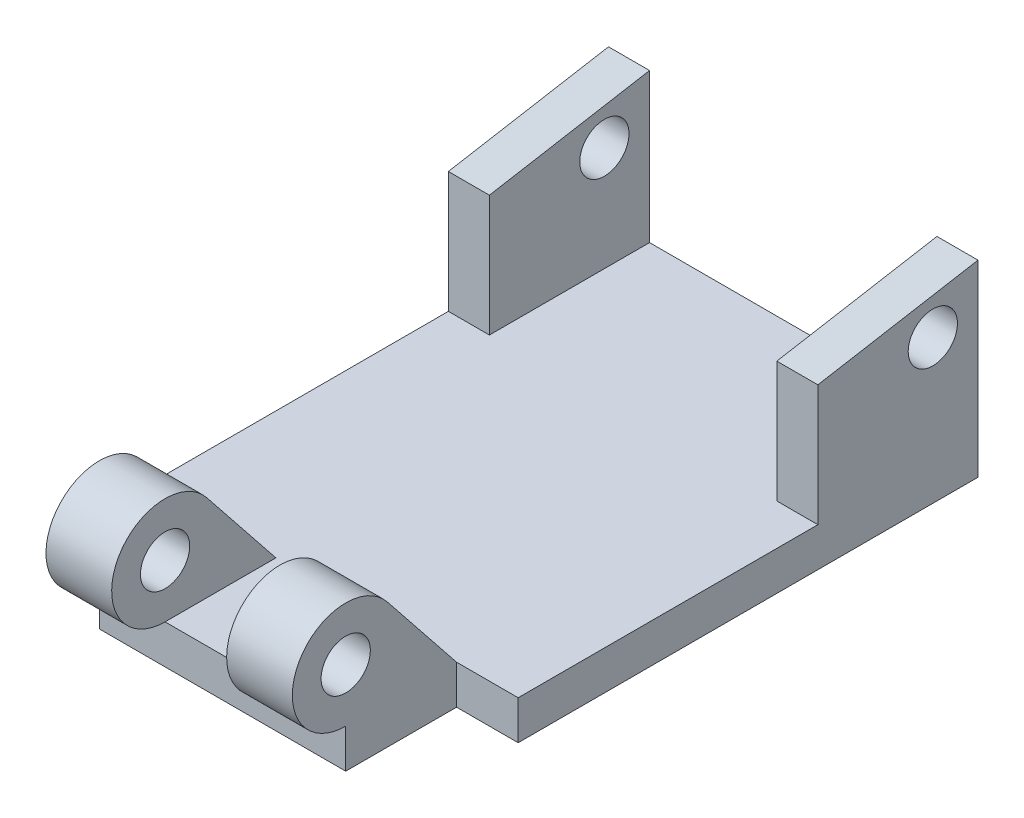
from build123d import *

# Parameters (mm, degrees)
SKETCH1_W           = 57.15
SKETCH1_H           = 71.12
SKETCH1_W_2         = 38.1
SKETCH1_H_2         = 17.145
BOSS_EXTRUDE1_DEPTH = 6.0325
SKETCH2_R           = 8.255
SKETCH2_R_2         = 3.81
BOSS_EXTRUDE2_DEPTH = 38.1
SKETCH3_W           = 17.78
SKETCH3_H           = 25.4
CUT_EXTRUDE1_DEPTH  = 35.7505
SKETCH4_R           = 3.81
BOSS_EXTRUDE3_DEPTH = 57.15
SKETCH5_W           = 44.45
SKETCH5_H           = 23.0505
CUT_EXTRUDE2_DEPTH  = 35.7505


with BuildPart() as part:
    # Sketch1 → Boss-Extrude1 (new body)
    with BuildSketch(Plane(origin=(0, 0, 0), x_dir=(1, 0, 0), z_dir=(0, 1, 0))):
        with Locations((28.575, 35.56)):
            Rectangle(SKETCH1_W, SKETCH1_H)
        with Locations((28.575, -8.5725)):
            Rectangle(SKETCH1_W_2, SKETCH1_H_2)
    extrude(amount=BOSS_EXTRUDE1_DEPTH)

    # Sketch2 → Boss-Extrude2 (add)
    with BuildSketch(Plane.ZY.offset(-9.525)):
        with BuildLine():
            Line((10.691759465, 19.435384187), (0, 6.0325))
            Line((0, 6.0325), (17.145, 6.0325))
            ThreePointArc((17.145, 6.0325), (9.707231216, 10.706352067), (10.691759465, 19.435384187))
        make_face()
        with Locations((17.145, 14.2875)):
            Circle(SKETCH2_R)
        with Locations((17.145, 14.2875)):
            Circle(SKETCH2_R_2, mode=Mode.SUBTRACT)
    extrude(amount=-BOSS_EXTRUDE2_DEPTH)

    # Sketch3 → Cut-Extrude1 (cut)
    with BuildSketch(Plane(origin=(0, 6.0325, 0), x_dir=(1, 0, 0), z_dir=(0, 1, 0))):
        with Locations((28.575, -12.7)):
            Rectangle(SKETCH3_W, SKETCH3_H)
    extrude(amount=CUT_EXTRUDE1_DEPTH, mode=Mode.SUBTRACT)

    # Sketch4 → Boss-Extrude3 (add)
    with BuildSketch(Plane.ZY):
        Polygon((-46.355, 6.0325), (-46.355, 24.765), (-71.12, 29.083), (-71.12, 6.0325), align=None)
        with Locations((-64.135, 22.225)):
            Circle(SKETCH4_R, mode=Mode.SUBTRACT)
    extrude(amount=-BOSS_EXTRUDE3_DEPTH)

    # Sketch5 → Cut-Extrude2 (cut)
    with BuildSketch(Plane(origin=(0, 0, -71.12), x_dir=(-1, 0, 0), z_dir=(0, 0, -1))):
        with Locations((-28.575, 17.55775)):
            Rectangle(SKETCH5_W, SKETCH5_H)
    extrude(amount=-CUT_EXTRUDE2_DEPTH, mode=Mode.SUBTRACT)


solid = part.part
